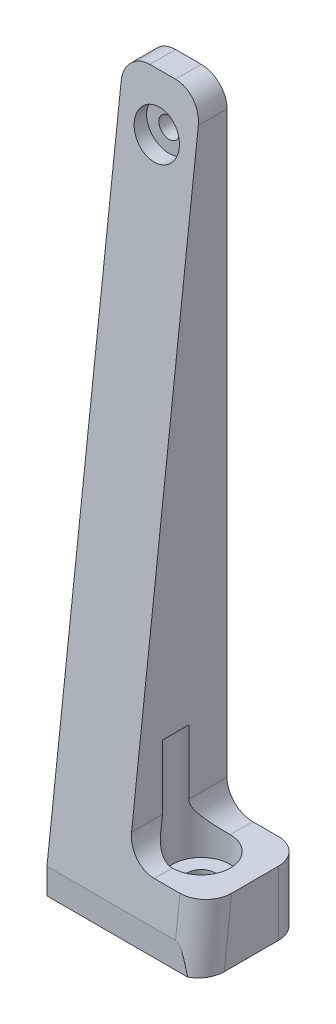
from build123d import *

# Parameters (mm, degrees)
ESQUISSE1_W             = 12
ESQUISSE1_H             = 108
ESQUISSE1_R             = 1.6
BOSS_EXTRU_1_DEPTH      = 4
ESQUISSE2_R             = 2.2
BOSS_EXTRU_2_DEPTH      = 4
BOSS_EXTRU_3_DEPTH      = 12
ESQUISSE4_W             = 12
ESQUISSE4_H             = 16
ESQUISSE4_R             = 2.2
BOSS_EXTRU_4_DEPTH      = 6
ENL_V_MAT_EXTRU_1_DEPTH = 13
ESQUISSE6_R             = 4.5
ENL_V_MAT_EXTRU_2_DEPTH = 14
ESQUISSE8_R             = 4.5
ENL_V_MAT_EXTRU_3_DEPTH = 4
ESQUISSE9_R             = 1.6
ENL_V_MAT_EXTRU_4_DEPTH = 17
ESQUISSE10_R            = 3.5
ENL_V_MAT_EXTRU_5_DEPTH = 14
CONG_1_R                = 4
CONG_2_R                = 4
CONG_3_R                = 4


with BuildPart() as part:
    # Esquisse1 → Boss.-Extru.1 (new body)
    with BuildSketch(Plane.XY):
        with Locations((-47.5, 54)):
            Rectangle(ESQUISSE1_W, ESQUISSE1_H)
        with Locations((-47.5, 100)):
            Circle(ESQUISSE1_R, mode=Mode.SUBTRACT)
    extrude(amount=BOSS_EXTRU_1_DEPTH)

    # Esquisse2 → Boss.-Extru.2 (add)
    with BuildSketch(Plane.XZ):
        Polygon((-41.5, 0), (-29.5, 0), (-29.5, 16), (-53.5, 16), (-53.5, 4), (-41.5, 4), align=None)
        with Locations((-37.5, 8)):
            Circle(ESQUISSE2_R, mode=Mode.SUBTRACT)
    extrude(amount=-BOSS_EXTRU_2_DEPTH)

    # Esquisse3 → Boss.-Extru.3 (add)
    with BuildSketch(Plane.ZY.offset(53.5)):
        Polygon((4, 108), (16, 4), (4, 4), align=None)
    extrude(amount=-BOSS_EXTRU_3_DEPTH)

    # Esquisse4 → Boss.-Extru.4 (add)
    with BuildSketch(Plane(origin=(0, 4, 0), x_dir=(1, 0, 0), z_dir=(0, 1, 0))):
        with Locations((-35.5, -8)):
            Rectangle(ESQUISSE4_W, ESQUISSE4_H)
        with Locations((-37.5, -8)):
            Circle(ESQUISSE4_R, mode=Mode.SUBTRACT)
    extrude(amount=BOSS_EXTRU_4_DEPTH)

    # Esquisse5 → Enlèv. mat.-Extru.1 (cut, through all)
    with BuildSketch(Plane.ZY.offset(41.5)):
        Polygon((15.307692308, 10), (16, 4), (16, 10), align=None)
    extrude(amount=-ENL_V_MAT_EXTRU_1_DEPTH, mode=Mode.SUBTRACT)

    # Esquisse6 → Enlèv. mat.-Extru.2 (cut)
    with BuildSketch(Plane(origin=(0, 10, 0), x_dir=(1, 0, 0), z_dir=(0, 1, 0))):
        with Locations((-37.5, -8)):
            Circle(ESQUISSE6_R)
    extrude(amount=ENL_V_MAT_EXTRU_2_DEPTH, mode=Mode.SUBTRACT)

    # Esquisse8 → Enlèv. mat.-Extru.3 (cut)
    with BuildSketch(Plane(origin=(0, 10, 0), x_dir=(1, 0, 0), z_dir=(0, 1, 0))):
        with Locations((-37.5, -8)):
            Circle(ESQUISSE8_R)
    extrude(amount=-ENL_V_MAT_EXTRU_3_DEPTH, mode=Mode.SUBTRACT)

    # Esquisse9 → Enlèv. mat.-Extru.4 (cut, through all)
    with BuildSketch(Plane(origin=(0, 0, 0), x_dir=(-1, 0, 0), z_dir=(0, 0, -1))):
        with Locations((47.5, 100)):
            Circle(ESQUISSE9_R)
    extrude(amount=-ENL_V_MAT_EXTRU_4_DEPTH, mode=Mode.SUBTRACT)

    # Esquisse10 → Enlèv. mat.-Extru.5 (cut, through all)
    with BuildSketch(Plane(origin=(0, 0, 3), x_dir=(-1, 0, 0), z_dir=(0, 0, -1))):
        with Locations((47.5, 100)):
            Circle(ESQUISSE10_R)
    extrude(amount=-ENL_V_MAT_EXTRU_5_DEPTH, mode=Mode.SUBTRACT)

    # Congé1
    cong_1_edges = [part.edges().sort_by_distance(p)[0] for p in [
        (-41.5, 108, 2),
        (-53.5, 108, 2),
    ]]
    fillet(cong_1_edges, radius=CONG_1_R)

    # Congé2
    cong_2_edges = [part.edges().sort_by_distance(p)[0] for p in [
        (-41.5, 10, 2.969223594),
        (-41.5, 10, 12.68462256),
    ]]
    fillet(cong_2_edges, radius=CONG_2_R)

    # Congé3
    cong_3_edges = [part.edges().sort_by_distance(p)[0] for p in [
        (-29.5, 5, 0),
        (-29.5, 7, 15.653846154),
    ]]
    fillet(cong_3_edges, radius=CONG_3_R)


solid = part.part
